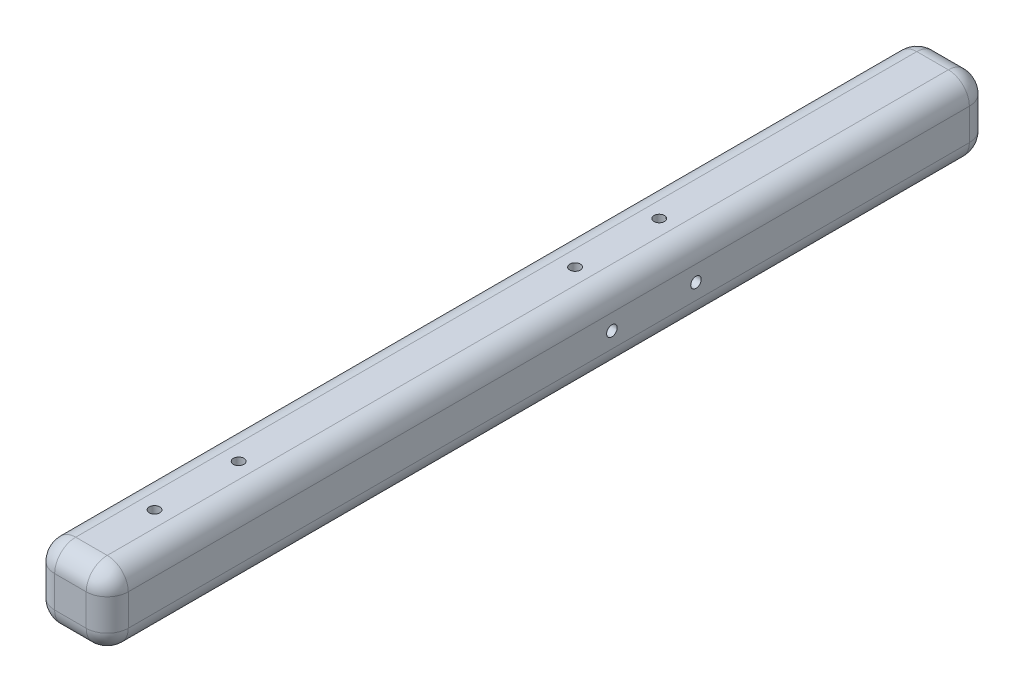
from build123d import *

# Parameters (mm, degrees)
BOSS_EXTRUDE1_DEPTH = 254
FILLET1_R           = 12.7
SKETCH2_R           = 3.175
CUT_EXTRUDE1_DEPTH  = 12.7
CIRPATTERN2_COUNT   = 2
CIRPATTERN2_ANGLE   = 90
BOSS_EXTRUDE2_DEPTH = 279.4
FILLET2_R           = 12.7
SKETCH6_R           = 3.175
CUT_EXTRUDE3_DEPTH  = 12.7


with BuildPart() as part:
    # Sketch1 → Boss-Extrude1 (new body)
    with BuildSketch(Plane.XY):
        with BuildLine():
            Line((-9.525, -22.225), (9.525, -22.225))
            ThreePointArc((9.525, -22.225), (18.505256121, -18.505256121), (22.225, -9.525))
            Line((22.225, -9.525), (22.225, 9.525))
            ThreePointArc((22.225, 9.525), (18.505256121, 18.505256121), (9.525, 22.225))
            Line((9.525, 22.225), (-9.525, 22.225))
            ThreePointArc((-9.525, 22.225), (-18.505256121, 18.505256121), (-22.225, 9.525))
            Line((-22.225, 9.525), (-22.225, -9.525))
            ThreePointArc((-22.225, -9.525), (-18.505256121, -18.505256121), (-9.525, -22.225))
        make_face()
    extrude(amount=BOSS_EXTRUDE1_DEPTH)

    # Fillet1
    fillet1_edges = [part.edges().sort_by_distance(p)[0] for p in [
        (0, -22.225, 0),
        (-18.505256121, -18.505256121, 0),
        (-22.225, 0, 0),
        (-18.505256121, 18.505256121, 0),
        (0, 22.225, 0),
        (18.505256121, 18.505256121, 0),
        (22.225, 0, 0),
        (18.505256121, -18.505256121, 0),
    ]]
    fillet(fillet1_edges, radius=FILLET1_R)

    # Sketch2 → Cut-Extrude1 (cut)
    with BuildSketch(Plane(origin=(0, 22.225, 0), x_dir=(1, 0, 0), z_dir=(0, 1, 0))):
        with Locations(Location((0, -177.8, 0), (0, 0, 270))):  # turned: the seam where the file's is
            Circle(SKETCH2_R)
        with Locations(Location((0, -228.6, 0), (0, 0, 270))):  # turned: the seam where the file's is
            Circle(SKETCH2_R)
    cut_extrude1 = extrude(amount=-CUT_EXTRUDE1_DEPTH, mode=Mode.SUBTRACT)

    # CirPattern2: Cut-Extrude1 ×2 about axis
    cirpattern2_axis = Axis((0, 0, 1052.131449431), (0, 0, -1))
    for i in range(1, CIRPATTERN2_COUNT):
        add(cut_extrude1.rotate(cirpattern2_axis, i * CIRPATTERN2_ANGLE / (CIRPATTERN2_COUNT - 1)), mode=Mode.SUBTRACT)

    # Sketch4 → Boss-Extrude2 (add)
    with BuildSketch(Plane.XY.offset(254)):
        with BuildLine():
            Line((-9.525, -22.225), (9.525, -22.225))
            ThreePointArc((9.525, -22.225), (18.505256121, -18.505256121), (22.225, -9.525))
            Line((22.225, -9.525), (22.225, 9.525))
            ThreePointArc((22.225, 9.525), (18.505256121, 18.505256121), (9.525, 22.225))
            Line((9.525, 22.225), (-9.525, 22.225))
            ThreePointArc((-9.525, 22.225), (-18.505256121, 18.505256121), (-22.225, 9.525))
            Line((-22.225, 9.525), (-22.225, -9.525))
            ThreePointArc((-22.225, -9.525), (-18.505256121, -18.505256121), (-9.525, -22.225))
        make_face()
    extrude(amount=BOSS_EXTRUDE2_DEPTH)

    # Fillet2
    fillet2_edges = [part.edges().sort_by_distance(p)[0] for p in [
        (-18.505256121, -18.505256121, 533.4),
        (0, -22.225, 533.4),
        (18.505256121, -18.505256121, 533.4),
        (22.225, 0, 533.4),
        (18.505256121, 18.505256121, 533.4),
        (0, 22.225, 533.4),
        (-18.505256121, 18.505256121, 533.4),
        (-22.225, 0, 533.4),
    ]]
    fillet(fillet2_edges, radius=FILLET2_R)

    # Sketch6 → Cut-Extrude3 (cut)
    with BuildSketch(Plane(origin=(0, 22.225, 0), x_dir=(1, 0, 0), z_dir=(0, 1, 0))):
        with Locations(Location((0, -431.8, 0), (0, 0, 270))):  # turned: the seam where the file's is
            Circle(SKETCH6_R)
        with Locations(Location((0, -482.6, 0), (0, 0, 270))):  # turned: the seam where the file's is
            Circle(SKETCH6_R)
    extrude(amount=-CUT_EXTRUDE3_DEPTH, mode=Mode.SUBTRACT)


solid = part.part
